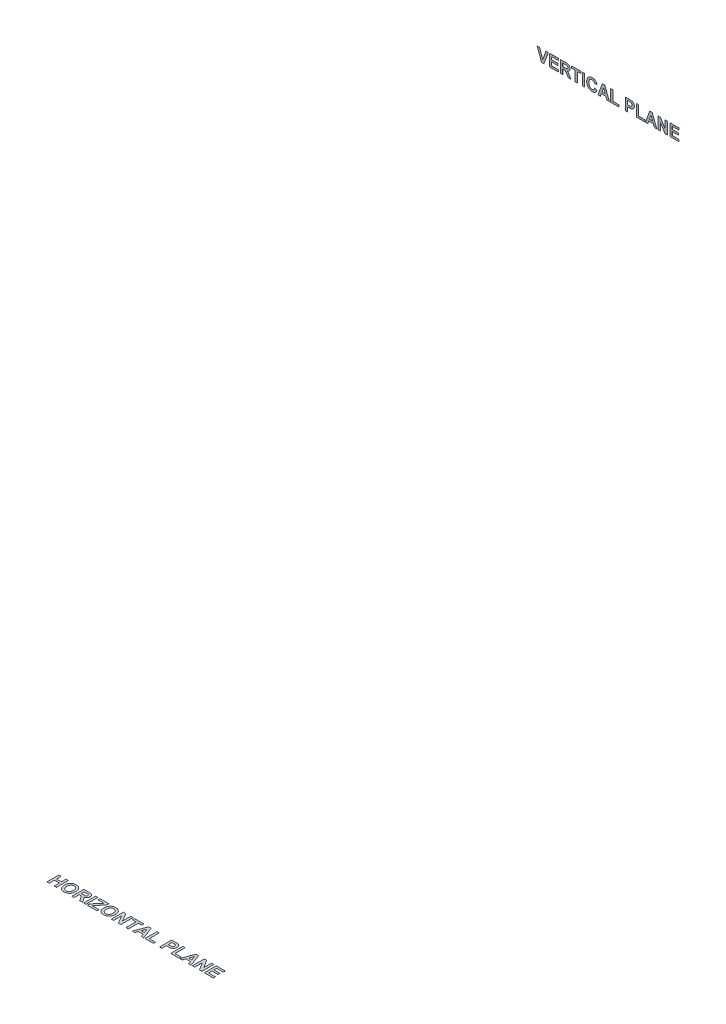
from build123d import *

# Parameters (mm, degrees)
VERTICAL_PLANE_TEXT_DEPTH      = 0.01
VERTICAL_PLANE_TEXT_2_DEPTH    = 0.01
VERTICAL_PLANE_TEXT_3_DEPTH    = 0.01
VERTICAL_PLANE_TEXT_4_DEPTH    = 0.01
SKETCH6_W                      = 0.673076923
SKETCH6_H                      = 3.5
VERTICAL_PLANE_TEXT_5_DEPTH    = 0.01
VERTICAL_PLANE_TEXT_6_DEPTH    = 0.01
VERTICAL_PLANE_TEXT_7_DEPTH    = 0.01
VERTICAL_PLANE_TEXT_8_DEPTH    = 0.01
VERTICAL_PLANE_TEXT_9_DEPTH    = 0.01
VERTICAL_PLANE_TEXT_10_DEPTH   = 0.01
VERTICAL_PLANE_TEXT_11_DEPTH   = 0.01
VERTICAL_PLANE_TEXT_12_DEPTH   = 0.01
VERTICAL_PLANE_TEXT_13_DEPTH   = 0.01
HORIZONTAL_PLANE_TEXT_DEPTH    = 0.01
HORIZONTAL_PLANE_TEXT_2_DEPTH  = 0.01
HORIZONTAL_PLANE_TEXT_3_DEPTH  = 0.01
SKETCH7_W                      = 0.673076923
SKETCH7_H                      = 3.5
HORIZONTAL_PLANE_TEXT_4_DEPTH  = 0.01
HORIZONTAL_PLANE_TEXT_5_DEPTH  = 0.01
HORIZONTAL_PLANE_TEXT_6_DEPTH  = 0.01
HORIZONTAL_PLANE_TEXT_7_DEPTH  = 0.01
HORIZONTAL_PLANE_TEXT_8_DEPTH  = 0.01
HORIZONTAL_PLANE_TEXT_9_DEPTH  = 0.01
HORIZONTAL_PLANE_TEXT_10_DEPTH = 0.01
HORIZONTAL_PLANE_TEXT_11_DEPTH = 0.01
HORIZONTAL_PLANE_TEXT_12_DEPTH = 0.01
HORIZONTAL_PLANE_TEXT_13_DEPTH = 0.01
HORIZONTAL_PLANE_TEXT_14_DEPTH = 0.01
HORIZONTAL_PLANE_TEXT_15_DEPTH = 0.01


with BuildPart() as part:
    # Sketch6 → Vertical  Plane text (new body)
    with BuildSketch(Plane.XY):
        Polygon((162.928886218, 140), (161.634615385, 143.5), (162.345552885, 143.5), (163.272435897, 140.897435897), (164.195813301, 143.5), (164.91025641, 143.5), (163.620893429, 140), align=None)
    extrude(amount=VERTICAL_PLANE_TEXT_DEPTH)


with BuildPart() as body_2:
    # Sketch6 → Vertical Plane text 2 (new body)
    with BuildSketch(Plane.XY):
        Polygon((165.224358974, 140), (165.224358974, 143.5), (167.826923077, 143.5), (167.826923077, 142.916666667), (165.897435897, 142.916666667), (165.897435897, 142.153846154), (167.692307692, 142.153846154), (167.692307692, 141.570512821), (165.897435897, 141.570512821), (165.897435897, 140.583333333), (167.871794872, 140.583333333), (167.871794872, 140), align=None)
    extrude(amount=VERTICAL_PLANE_TEXT_2_DEPTH)


with BuildPart() as body_3:
    # Sketch6 → Vertical Plane text 3 (new body)
    with BuildSketch(Plane.XY):
        with BuildLine():
            Line((168.455128205, 140), (168.455128205, 143.5))
            Line((168.455128205, 143.5), (169.923978365, 143.5))
            add(Edge.make_bspline(
                [(169.923978365, 143.5), (169.968618174, 143.499724886), (170.054647254, 143.499194691), (170.179062088, 143.495328401), (170.293800492, 143.487228299), (170.399371448, 143.478054866), (170.49526789, 143.464708113), (170.581868975, 143.448718835), (170.659028904, 143.430189465), (170.727873486, 143.40799754), (170.79064576, 143.382598111), (170.849121213, 143.352365645), (170.9039428, 143.316944595), (170.955952526, 143.277555827), (171.005370633, 143.234138819), (171.050842337, 143.185544544), (171.093159877, 143.132496584), (171.132289108, 143.075436302), (171.166759511, 143.014615654), (171.198256409, 142.951987908), (171.223896072, 142.886886612), (171.245074201, 142.819618441), (171.261991617, 142.750329442), (171.273733733, 142.678843459), (171.281064209, 142.605289882), (171.281718602, 142.555606574), (171.282051282, 142.530348558)],
                knots=[0, 0, 0, 0, 1.675828044, 3.229627355, 4.67171229, 5.993455049, 7.206927059, 8.304770529, 9.29850117, 10.183580433, 11.017754134, 11.837875825, 12.650738409, 13.464925643, 14.285328857, 15.117007378, 15.959673368, 16.830859064, 17.711229498, 18.58228265, 19.460420693, 20.334473227, 21.228207035, 22.135446768, 23.052097822, 24, 24, 24, 24], degree=3))
            add(Edge.make_bspline(
                [(171.282051282, 142.530348558), (171.28143421, 142.498530526), (171.280228281, 142.436349323), (171.269130685, 142.345211031), (171.252647921, 142.258134898), (171.229151868, 142.175000289), (171.196845273, 142.096784985), (171.159341265, 142.022393301), (171.114611436, 141.952077575), (171.062959675, 141.88653488), (171.004432224, 141.825707197), (170.938772594, 141.770846314), (170.866449573, 141.721737821), (170.787025652, 141.678664908), (170.701053862, 141.641842234), (170.608161404, 141.610860758), (170.5087688, 141.585645288), (170.43963136, 141.573780656), (170.404246795, 141.567708333)],
                knots=[0, 0, 0, 0, 1.05911256, 2.069797862, 3.05271628, 4.008392045, 4.940519534, 5.866323021, 6.779546087, 7.71056835, 8.640711998, 9.585328432, 10.554502533, 11.547017206, 12.589327225, 13.664782803, 14.804835066, 16, 16, 16, 16], degree=3))
            add(Edge.make_bspline(
                [(170.404246795, 141.567708333), (170.438467643, 141.545043544), (170.505442505, 141.500685463), (170.598107047, 141.427627148), (170.68129782, 141.350946796), (170.744285676, 141.282757856), (170.792685353, 141.222793009), (170.831655362, 141.170347176), (170.873690764, 141.109989629), (170.918379283, 141.041687666), (170.967042025, 140.966045596), (171.017869136, 140.881905603), (171.071924245, 140.790088399), (171.108267738, 140.725949433), (171.127103365, 140.692708333)],
                knots=[0, 0, 0, 0, 1.285445069, 2.515791127, 3.691898215, 4.826622834, 5.420063933, 6.105349801, 6.873086501, 7.723915395, 8.66222816, 9.690593598, 10.803111229, 12, 12, 12, 12], degree=3))
            Line((171.127103365, 140.692708333), (171.551282051, 140))
            Line((171.551282051, 140), (170.764623397, 140))
            Line((170.764623397, 140), (170.266826923, 140.794370994))
            add(Edge.make_bspline(
                [(170.266826923, 140.794370994), (170.243965141, 140.826184979), (170.2003173, 140.886924416), (170.137308944, 140.973237129), (170.079661891, 141.050070946), (170.02891032, 141.11853876), (169.982486224, 141.176699348), (169.941799223, 141.225566247), (169.907678058, 141.266188071), (169.869069876, 141.306466362), (169.824153355, 141.347861226), (169.768550289, 141.387995903), (169.7114511, 141.419990844), (169.650273879, 141.444403736), (169.579524272, 141.461426026), (169.49447204, 141.472271389), (169.392442942, 141.480272976), (169.318696345, 141.480595427), (169.278946314, 141.480769231)],
                knots=[0, 0, 0, 0, 1.465447777, 2.797841088, 3.997266218, 5.05856206, 5.985598736, 6.780315439, 7.437430484, 7.969193402, 8.866571936, 9.718200644, 10.52825214, 11.309096006, 12.174169268, 13.242355782, 14.513606761, 16, 16, 16, 16], degree=3))
            Line((169.278946314, 141.480769231), (169.128205128, 141.480769231))
            Line((169.128205128, 141.480769231), (169.128205128, 140))
            Line((169.128205128, 140), (168.455128205, 140))
        make_face()
        with BuildLine():
            Line((169.128205128, 142.064102564), (169.670172276, 142.064102564))
            add(Edge.make_bspline(
                [(169.670172276, 142.064102564), (169.712007896, 142.06419222), (169.791711822, 142.064363031), (169.90505239, 142.06683715), (170.006303682, 142.068937078), (170.094859785, 142.074213237), (170.171116906, 142.079442407), (170.234769139, 142.086238432), (170.286352772, 142.094271114), (170.337876151, 142.106759825), (170.390653597, 142.128518938), (170.44690437, 142.159510321), (170.494980513, 142.199714548), (170.536625557, 142.246194701), (170.568394891, 142.300836348), (170.593277794, 142.361205142), (170.605893953, 142.428642531), (170.607926042, 142.475385424), (170.608974359, 142.499499199)],
                knots=[0, 0, 0, 0, 1.697953026, 3.23488743, 4.60134403, 5.807846676, 6.835100678, 7.703488618, 8.405232423, 8.952775585, 9.851109663, 10.713519226, 11.549115941, 12.382556273, 13.233359028, 14.101746968, 15.020727134, 16, 16, 16, 16], degree=3))
            add(Edge.make_bspline(
                [(170.608974359, 142.499499199), (170.607782096, 142.526475442), (170.605481816, 142.578521752), (170.587341486, 142.652584149), (170.555678277, 142.718008079), (170.512192674, 142.774901559), (170.457603349, 142.822943235), (170.392581428, 142.861077869), (170.317609975, 142.889478961), (170.263535722, 142.89996743), (170.235276442, 142.905448718)],
                knots=[0, 0, 0, 0, 1.062977961, 2.050844577, 2.982300261, 3.90936959, 4.856017476, 5.831122378, 6.86654153, 8, 8, 8, 8], degree=3))
            add(Edge.make_bspline(
                [(170.235276442, 142.905448718), (170.225935309, 142.906475108), (170.203794861, 142.908907867), (170.164697454, 142.910470322), (170.114706404, 142.912871985), (170.053216619, 142.913853491), (169.980777445, 142.915573984), (169.897100831, 142.91588991), (169.802452625, 142.916899272), (169.735610715, 142.91674704), (169.700320513, 142.916666667)],
                knots=[0, 0, 0, 0, 0.42127143, 0.998501726, 1.753681744, 2.66564073, 3.755712164, 5.002818897, 6.417592707, 8, 8, 8, 8], degree=3))
            Line((169.700320513, 142.916666667), (169.128205128, 142.916666667))
            Line((169.128205128, 142.916666667), (169.128205128, 142.064102564))
        make_face(mode=Mode.SUBTRACT)
    extrude(amount=VERTICAL_PLANE_TEXT_3_DEPTH)


with BuildPart() as body_4:
    # Sketch6 → Vertical Plane text 4 (new body)
    with BuildSketch(Plane.XY):
        Polygon((172.762820513, 140), (172.762820513, 142.916666667), (171.730769231, 142.916666667), (171.730769231, 143.5), (174.467948718, 143.5), (174.467948718, 142.916666667), (173.435897436, 142.916666667), (173.435897436, 140), align=None)
    extrude(amount=VERTICAL_PLANE_TEXT_4_DEPTH)


with BuildPart() as body_5:
    # Sketch6 → Vertical Plane text 5 (new body)
    with BuildSketch(Plane.XY):
        with Locations((175.208333334, 141.75)):
            Rectangle(SKETCH6_W, SKETCH6_H)
    extrude(amount=VERTICAL_PLANE_TEXT_5_DEPTH)


with BuildPart() as body_6:
    # Sketch6 → Vertical Plane text 6 (new body)
    with BuildSketch(Plane.XY):
        with BuildLine():
            Line((178.506410256, 141.301282051), (179.179487179, 141.076923077))
            add(Edge.make_bspline(
                [(179.179487179, 141.076923077), (179.165808185, 141.032791119), (179.13902041, 140.946366861), (179.089833565, 140.82250038), (179.03358917, 140.707707664), (178.972309898, 140.600645141), (178.902184914, 140.504078584), (178.827140184, 140.414810732), (178.744944331, 140.334721735), (178.656002931, 140.263640574), (178.561172095, 140.200781957), (178.459350261, 140.147641881), (178.352056977, 140.10187371), (178.238204228, 140.064791842), (178.118547618, 140.035094895), (177.992525709, 140.015479899), (177.860728019, 140.002180285), (177.770734663, 140.000738283), (177.724659455, 140)],
                knots=[0, 0, 0, 0, 1.126640671, 2.206316847, 3.246446654, 4.24268115, 5.210795778, 6.153057602, 7.084219323, 8.004711971, 8.926421631, 9.854560063, 10.802134612, 11.768317461, 12.772025444, 13.805668576, 14.876536225, 16, 16, 16, 16], degree=3))
            add(Edge.make_bspline(
                [(177.724659455, 140), (177.667789026, 140.001175957), (177.555923193, 140.0034891), (177.392330006, 140.026774076), (177.236433097, 140.063104192), (177.088009443, 140.113402605), (176.948049754, 140.180022725), (176.815277119, 140.260224713), (176.690657809, 140.3556368), (176.574629011, 140.464650924), (176.469214042, 140.58643488), (176.378057365, 140.720330582), (176.300167136, 140.864451767), (176.237212237, 141.019485619), (176.187985755, 141.185272947), (176.153502502, 141.361584522), (176.131925075, 141.548475884), (176.129466775, 141.676554972), (176.128205128, 141.74228766)],
                knots=[0, 0, 0, 0, 1.025049111, 2.016302254, 2.973197159, 3.90886983, 4.83646737, 5.763135642, 6.70136783, 7.661478232, 8.629732022, 9.600038443, 10.576877021, 11.5787097, 12.612181225, 13.690866959, 14.814907849, 16, 16, 16, 16], degree=3))
            add(Edge.make_bspline(
                [(176.128205128, 141.74228766), (176.129461089, 141.811525037), (176.131911238, 141.946594525), (176.153529088, 142.142973997), (176.187089512, 142.328050202), (176.236399194, 142.500675592), (176.298428961, 142.662065046), (176.376413756, 142.810616464), (176.466661149, 142.948310441), (176.571597693, 143.072623216), (176.688155279, 143.18299615), (176.813061148, 143.280595663), (176.947480561, 143.362474657), (177.090677943, 143.429431013), (177.242845349, 143.481245137), (177.403683353, 143.518555374), (177.57332355, 143.54027233), (177.689307395, 143.543317665), (177.748497596, 143.544871795)],
                knots=[0, 0, 0, 0, 1.212648312, 2.365655595, 3.457000981, 4.504219827, 5.506356588, 6.480637568, 7.437950897, 8.385265166, 9.323599949, 10.245787653, 11.157260172, 12.074946661, 13.00980897, 13.968233668, 14.963125779, 16, 16, 16, 16], degree=3))
            add(Edge.make_bspline(
                [(177.748497596, 143.544871795), (177.800190686, 143.543569263), (177.901541869, 143.541015476), (178.049960384, 143.523664953), (178.190619601, 143.493215945), (178.324279829, 143.452116554), (178.4501802, 143.397876291), (178.568546265, 143.331595248), (178.679784875, 143.25362412), (178.746808428, 143.192719435), (178.780548878, 143.162059295)],
                knots=[0, 0, 0, 0, 1.098510076, 2.153775193, 3.169777012, 4.153122333, 5.120892526, 6.076995459, 7.031936742, 8, 8, 8, 8], degree=3))
            add(Edge.make_bspline(
                [(178.780548878, 143.162059295), (178.8001044, 143.142549936), (178.839674789, 143.103072959), (178.892512365, 143.036424635), (178.942608951, 142.964677704), (178.989169415, 142.886608253), (179.030722183, 142.801626311), (179.069266815, 142.711036932), (179.104753411, 142.614490923), (179.124488039, 142.547300866), (179.134615385, 142.512820513)],
                knots=[0, 0, 0, 0, 0.885292881, 1.791380647, 2.722937556, 3.69093542, 4.703306561, 5.754477758, 6.847650944, 8, 8, 8, 8], degree=3))
            Line((179.134615385, 142.512820513), (178.461538462, 142.378205128))
            add(Edge.make_bspline(
                [(178.461538462, 142.378205128), (178.455817584, 142.40028209), (178.444548957, 142.443767913), (178.421748424, 142.506254653), (178.395594414, 142.565548989), (178.363178915, 142.620198594), (178.328745272, 142.672634677), (178.287977782, 142.720528912), (178.24348, 142.765136503), (178.194931371, 142.805994531), (178.142910664, 142.842277396), (178.088419462, 142.874893432), (178.030467366, 142.901518308), (177.969825281, 142.923057771), (177.906734739, 142.941116988), (177.840634041, 142.952273008), (177.772090914, 142.960837226), (177.725390054, 142.96130129), (177.701522436, 142.961538462)],
                knots=[0, 0, 0, 0, 1.051226935, 2.070641259, 3.064374968, 4.034983734, 4.997599858, 5.953980297, 6.92954377, 7.901109626, 8.875958313, 9.851998019, 10.826131395, 11.811470594, 12.818270757, 13.847890818, 14.900111925, 16, 16, 16, 16], degree=3))
            add(Edge.make_bspline(
                [(177.701522436, 142.961538462), (177.668744689, 142.9608765), (177.604772335, 142.95958455), (177.511266938, 142.945180183), (177.422145667, 142.925077397), (177.337767944, 142.894380547), (177.258656297, 142.85511953), (177.183911618, 142.807393373), (177.113944146, 142.7514065), (177.048730232, 142.68649565), (176.990209609, 142.611487203), (176.938761628, 142.526226294), (176.896080915, 142.429744935), (176.861430965, 142.322989913), (176.834157506, 142.205707362), (176.814682109, 142.077746862), (176.803911629, 141.939020874), (176.802177491, 141.84303359), (176.801282051, 141.793469551)],
                knots=[0, 0, 0, 0, 0.938194206, 1.831074359, 2.704771284, 3.551924377, 4.396294915, 5.230222094, 6.087631332, 6.958733431, 7.860107878, 8.806247581, 9.804197948, 10.875520245, 12.017191412, 13.250061517, 14.580040491, 16, 16, 16, 16], degree=3))
            add(Edge.make_bspline(
                [(176.801282051, 141.793469551), (176.802168674, 141.740868404), (176.80387706, 141.639514095), (176.814645255, 141.493319878), (176.834245188, 141.358859874), (176.861156183, 141.235895464), (176.895980748, 141.124501963), (176.938589282, 141.024872138), (176.989242699, 140.93688931), (177.047862191, 140.860612065), (177.112965757, 140.795090147), (177.182790117, 140.738756215), (177.256923321, 140.690590926), (177.33581147, 140.650963631), (177.419754611, 140.620986023), (177.508062856, 140.599245737), (177.601060223, 140.585425091), (177.664780857, 140.584040358), (177.697315705, 140.583333333)],
                knots=[0, 0, 0, 0, 1.475208372, 2.842499301, 4.107722225, 5.282836115, 6.369007568, 7.375918121, 8.315702116, 9.208439171, 10.065831443, 10.90006451, 11.71996243, 12.54067204, 13.369972975, 14.214060185, 15.088124569, 16, 16, 16, 16], degree=3))
            add(Edge.make_bspline(
                [(177.697315705, 140.583333333), (177.72140332, 140.583934281), (177.768768038, 140.585115956), (177.838776744, 140.592615956), (177.905970823, 140.606928625), (177.97067917, 140.625854538), (178.033153198, 140.649600977), (178.092439972, 140.680062882), (178.149705935, 140.715074319), (178.203762864, 140.75610504), (178.255334607, 140.802169858), (178.302371097, 140.855409307), (178.346001347, 140.914544164), (178.38567184, 140.979969628), (178.422708095, 141.05112568), (178.454218729, 141.129120971), (178.483573709, 141.212695059), (178.498665118, 141.271237293), (178.506410256, 141.301282051)],
                knots=[0, 0, 0, 0, 0.980177776, 1.927374078, 2.859849964, 3.771585772, 4.668674471, 5.574490016, 6.479656464, 7.396337719, 8.332153134, 9.288470092, 10.28125149, 11.318486971, 12.398724812, 13.541284404, 14.738150009, 16, 16, 16, 16], degree=3))
        make_face()
    extrude(amount=VERTICAL_PLANE_TEXT_6_DEPTH)


with BuildPart() as body_7:
    # Sketch6 → Vertical Plane text 7 (new body)
    with BuildSketch(Plane.XY):
        Polygon((182.769230769, 140), (182.055488782, 140), (181.760316506, 140.807692308), (180.416967147, 140.807692308), (180.121794872, 140), (179.403846154, 140), (180.726862981, 143.5), (181.439903846, 143.5), align=None)
        Polygon((181.546474359, 141.391025641), (181.086538462, 142.647435897), (180.628004808, 141.391025641), align=None, mode=Mode.SUBTRACT)
    extrude(amount=VERTICAL_PLANE_TEXT_7_DEPTH)


with BuildPart() as body_8:
    # Sketch6 → Vertical Plane text 8 (new body)
    with BuildSketch(Plane.XY):
        Polygon((183.128205128, 140), (183.128205128, 143.5), (183.801282051, 143.5), (183.801282051, 140.583333333), (185.596153846, 140.583333333), (185.596153846, 140), align=None)
    extrude(amount=VERTICAL_PLANE_TEXT_8_DEPTH)


with BuildPart() as body_9:
    # Sketch6 → Vertical Plane text 9 (new body)
    with BuildSketch(Plane.XY):
        with BuildLine():
            Line((187.435897436, 140), (187.435897436, 143.5))
            Line((187.435897436, 143.5), (188.555588942, 143.5))
            add(Edge.make_bspline(
                [(188.555588942, 143.5), (188.606305077, 143.499944616), (188.703305712, 143.499838686), (188.841671252, 143.496895527), (188.966248691, 143.492729161), (189.076853137, 143.487540128), (189.173873777, 143.479797095), (189.256875388, 143.470830779), (189.326380625, 143.461185402), (189.3673102, 143.451203727), (189.385717147, 143.446714744)],
                knots=[0, 0, 0, 0, 1.460485487, 2.793352117, 3.985295279, 5.050041172, 5.981765236, 6.787433016, 7.454681457, 8, 8, 8, 8], degree=3))
            add(Edge.make_bspline(
                [(189.385717147, 143.446714744), (189.410193911, 143.439735475), (189.458774552, 143.425883262), (189.528375461, 143.396352545), (189.595459717, 143.362128019), (189.659184476, 143.32133857), (189.71976636, 143.274708355), (189.777385446, 143.22261765), (189.832349008, 143.164831306), (189.883896695, 143.101463476), (189.931108313, 143.032833695), (189.971911013, 142.958840494), (190.006095144, 142.879805486), (190.035219456, 142.796322609), (190.056707512, 142.707496792), (190.071745244, 142.613945206), (190.082213383, 142.515626933), (190.082954559, 142.448345926), (190.083333333, 142.41396234)],
                knots=[0, 0, 0, 0, 0.907145743, 1.80047177, 2.69161667, 3.591261238, 4.495029544, 5.415863088, 6.359363025, 7.337192411, 8.326890979, 9.326929023, 10.346104993, 11.395420813, 12.477187422, 13.601053412, 14.774031606, 16, 16, 16, 16], degree=3))
            add(Edge.make_bspline(
                [(190.083333333, 142.41396234), (190.082253071, 142.361746954), (190.080173508, 142.26122947), (190.056906879, 142.117125474), (190.021419548, 141.985495762), (189.969552248, 141.867608204), (189.906315235, 141.763000188), (189.836658364, 141.668696555), (189.757120453, 141.587539713), (189.671186757, 141.51821994), (189.580370545, 141.461491513), (189.489389938, 141.413131335), (189.397017285, 141.375950484), (189.334037816, 141.359750489), (189.302984776, 141.351762821)],
                knots=[0, 0, 0, 0, 1.312386234, 2.526415563, 3.661883817, 4.733421185, 5.753802465, 6.732107337, 7.675884281, 8.604170108, 9.50284679, 10.365392406, 11.194030444, 12, 12, 12, 12], degree=3))
            add(Edge.make_bspline(
                [(189.302984776, 141.351762821), (189.280820639, 141.347546681), (189.234101282, 141.338659561), (189.160007178, 141.329800721), (189.079018307, 141.31999495), (188.990801555, 141.313599075), (188.895463643, 141.307609607), (188.79304159, 141.304781781), (188.683681769, 141.301374825), (188.60841016, 141.301313606), (188.569611378, 141.301282051)],
                knots=[0, 0, 0, 0, 0.735353946, 1.55003838, 2.431865514, 3.394945452, 4.432993119, 5.54609699, 6.735134699, 8, 8, 8, 8], degree=3))
            Line((188.569611378, 141.301282051), (188.108974359, 141.301282051))
            Line((188.108974359, 141.301282051), (188.108974359, 140))
            Line((188.108974359, 140), (187.435897436, 140))
        make_face()
        with BuildLine():
            Line((188.108974359, 142.916666667), (188.108974359, 141.884615385))
            Line((188.108974359, 141.884615385), (188.512820513, 141.884615385))
            add(Edge.make_bspline(
                [(188.512820513, 141.884615385), (188.547645954, 141.884660481), (188.614271404, 141.884746755), (188.709864146, 141.887843498), (188.796394787, 141.891623646), (188.874044129, 141.897880566), (188.942343461, 141.906127036), (189.001750165, 141.915990853), (189.052333481, 141.926575759), (189.10703245, 141.944116645), (189.165516584, 141.972496198), (189.227970766, 142.013284745), (189.282836691, 142.062052263), (189.328492413, 142.119328024), (189.364961227, 142.182964713), (189.391072924, 142.252310161), (189.407933223, 142.32621507), (189.409473257, 142.377410916), (189.41025641, 142.403445513)],
                knots=[0, 0, 0, 0, 1.411705958, 2.700771114, 3.876961699, 4.922619712, 5.858038221, 6.66485904, 7.363650596, 7.950905807, 8.989198271, 9.987739806, 10.967313358, 11.951275539, 12.944273208, 13.927870418, 14.946261014, 16, 16, 16, 16], degree=3))
            add(Edge.make_bspline(
                [(189.41025641, 142.403445513), (189.409154208, 142.435155246), (189.407017184, 142.496636237), (189.383451773, 142.584195429), (189.347093036, 142.663656457), (189.295110366, 142.73254693), (189.232316523, 142.790478152), (189.161738864, 142.838678989), (189.081870172, 142.872410302), (189.025344546, 142.88547994), (188.996594551, 142.892127404)],
                knots=[0, 0, 0, 0, 1.085904563, 2.105425768, 3.088705091, 4.068969419, 5.045188284, 6.010769642, 6.988240112, 8, 8, 8, 8], degree=3))
            add(Edge.make_bspline(
                [(188.996594551, 142.892127404), (188.984222772, 142.894106169), (188.956761257, 142.898498414), (188.911114632, 142.903082269), (188.857114666, 142.907251279), (188.79469627, 142.910674162), (188.724106852, 142.913350063), (188.645113579, 142.915694813), (188.557924493, 142.915883183), (188.496927848, 142.91639827), (188.465144231, 142.916666667)],
                knots=[0, 0, 0, 0, 0.564603001, 1.253243608, 2.066786758, 3.005752288, 4.070476343, 5.250658742, 6.567396469, 8, 8, 8, 8], degree=3))
            Line((188.465144231, 142.916666667), (188.108974359, 142.916666667))
        make_face(mode=Mode.SUBTRACT)
    extrude(amount=VERTICAL_PLANE_TEXT_9_DEPTH)


with BuildPart() as body_10:
    # Sketch6 → Vertical Plane text 10 (new body)
    with BuildSketch(Plane.XY):
        Polygon((190.666666667, 140), (190.666666667, 143.5), (191.33974359, 143.5), (191.33974359, 140.583333333), (193.134615385, 140.583333333), (193.134615385, 140), align=None)
    extrude(amount=VERTICAL_PLANE_TEXT_10_DEPTH)


with BuildPart() as body_11:
    # Sketch6 → Vertical Plane text 11 (new body)
    with BuildSketch(Plane.XY):
        Polygon((196.634615385, 140), (195.920873397, 140), (195.625701122, 140.807692308), (194.282351763, 140.807692308), (193.987179487, 140), (193.269230769, 140), (194.592247596, 143.5), (195.305288462, 143.5), align=None)
        Polygon((195.411858974, 141.391025641), (194.951923077, 142.647435897), (194.493389423, 141.391025641), align=None, mode=Mode.SUBTRACT)
    extrude(amount=VERTICAL_PLANE_TEXT_11_DEPTH)


with BuildPart() as body_12:
    # Sketch6 → Vertical Plane text 12 (new body)
    with BuildSketch(Plane.XY):
        Polygon((196.993589744, 140), (196.993589744, 143.5), (197.696814904, 143.5), (199.102564103, 141.200320513), (199.102564103, 143.5), (199.775641026, 143.5), (199.775641026, 140), (199.051382212, 140), (197.666666667, 142.264623397), (197.666666667, 140), align=None)
    extrude(amount=VERTICAL_PLANE_TEXT_12_DEPTH)


with BuildPart() as body_13:
    # Sketch6 → Vertical Plane text 13 (new body)
    with BuildSketch(Plane.XY):
        Polygon((200.493589744, 140), (200.493589744, 143.5), (203.096153846, 143.5), (203.096153846, 142.916666667), (201.166666667, 142.916666667), (201.166666667, 142.153846154), (202.961538462, 142.153846154), (202.961538462, 141.570512821), (201.166666667, 141.570512821), (201.166666667, 140.583333333), (203.141025641, 140.583333333), (203.141025641, 140), align=None)
    extrude(amount=VERTICAL_PLANE_TEXT_13_DEPTH)


with BuildPart() as body_14:
    # Sketch7 → Horizontal Plane text (new body)
    with BuildSketch(Plane(origin=(0, 0, 0), x_dir=(1, 0, 0), z_dir=(0, 1, 0))):
        Polygon((158.224358974, -140), (158.224358974, -136.5), (158.897435897, -136.5), (158.897435897, -137.891025641), (160.333333333, -137.891025641), (160.333333333, -136.5), (161.006410256, -136.5), (161.006410256, -140), (160.333333333, -140), (160.333333333, -138.474358974), (158.897435897, -138.474358974), (158.897435897, -140), align=None)
    extrude(amount=HORIZONTAL_PLANE_TEXT_DEPTH)


with BuildPart() as body_15:
    # Sketch7 → Horizontal Plane text 2 (new body)
    with BuildSketch(Plane(origin=(0, 0, 0), x_dir=(1, 0, 0), z_dir=(0, 1, 0))):
        with BuildLine():
            add(Edge.make_bspline(
                [(161.58974359, -138.271033654), (161.58999127, -138.227782098), (161.590477683, -138.142841626), (161.598906091, -138.018230765), (161.610015388, -137.898786602), (161.628106861, -137.784978954), (161.649389038, -137.676275164), (161.676007393, -137.572707498), (161.708073085, -137.474639165), (161.733581596, -137.412023595), (161.74609375, -137.381310096)],
                knots=[0, 0, 0, 0, 1.141009212, 2.240794809, 3.294380675, 4.305229195, 5.280013876, 6.216333343, 7.125095522, 8, 8, 8, 8], degree=3))
            add(Edge.make_bspline(
                [(161.74609375, -137.381310096), (161.766546373, -137.3376473), (161.807211062, -137.250835255), (161.88273178, -137.128162856), (161.968330062, -137.012472844), (162.0633012, -136.904371714), (162.165220551, -136.805486868), (162.274568922, -136.720855678), (162.387461495, -136.647619968), (162.467753744, -136.61078676), (162.507512019, -136.592548077)],
                knots=[0, 0, 0, 0, 1.031372299, 2.050613973, 3.077158538, 4.108712802, 5.127684358, 6.111366908, 7.06480644, 8, 8, 8, 8], degree=3))
            add(Edge.make_bspline(
                [(162.507512019, -136.592548077), (162.534499787, -136.581478297), (162.589048948, -136.559103448), (162.673824765, -136.531178464), (162.761817216, -136.508490678), (162.852389858, -136.48821044), (162.946422075, -136.474226548), (163.043154047, -136.462501536), (163.143115156, -136.456356253), (163.210730118, -136.455542006), (163.245092147, -136.455128205)],
                knots=[0, 0, 0, 0, 0.92659354, 1.872881803, 2.832850937, 3.813025581, 4.820167273, 5.851730198, 6.908245912, 8, 8, 8, 8], degree=3))
            add(Edge.make_bspline(
                [(163.245092147, -136.455128205), (163.306620023, -136.456670507), (163.42703092, -136.459688813), (163.602917428, -136.481489677), (163.769359468, -136.518302443), (163.925793631, -136.571510534), (164.073568643, -136.638021804), (164.211536382, -136.720521459), (164.339901041, -136.818116603), (164.458414692, -136.929468891), (164.565144723, -137.054384265), (164.658097713, -137.191695829), (164.736072705, -137.340760129), (164.800289613, -137.501165889), (164.849635468, -137.673437045), (164.885287802, -137.857087516), (164.906468175, -138.052252577), (164.908971016, -138.186144453), (164.91025641, -138.254907853)],
                knots=[0, 0, 0, 0, 1.064641025, 2.083517118, 3.061799897, 4.009540929, 4.938075217, 5.861300345, 6.78508344, 7.723570974, 8.670267188, 9.622657076, 10.586935816, 11.576069104, 12.607749008, 13.683335114, 14.81022093, 16, 16, 16, 16], degree=3))
            add(Edge.make_bspline(
                [(164.91025641, -138.254907853), (164.909000705, -138.323210802), (164.90655608, -138.456183885), (164.884980363, -138.649817477), (164.850806122, -138.832129131), (164.800266294, -139.002702382), (164.737965991, -139.162838816), (164.659188617, -139.310631081), (164.568182343, -139.448039544), (164.461603902, -139.571608857), (164.345084904, -139.683600197), (164.216883068, -139.780054698), (164.079919667, -139.862666137), (163.932950352, -139.929369613), (163.776933041, -139.981481903), (163.611358582, -140.018577548), (163.436142058, -140.040294519), (163.316200319, -140.043323784), (163.254907853, -140.044871795)],
                knots=[0, 0, 0, 0, 1.18845052, 2.313691126, 3.386664782, 4.412527756, 5.405809582, 6.372003093, 7.321919452, 8.268293321, 9.206237639, 10.129603466, 11.054616372, 11.9847576, 12.932764752, 13.912672021, 14.933336461, 16, 16, 16, 16], degree=3))
            add(Edge.make_bspline(
                [(163.254907853, -140.044871795), (163.192915266, -140.043320212), (163.071577963, -140.040283318), (162.894492591, -140.018632452), (162.727274524, -139.981524596), (162.570042838, -139.929229), (162.421725182, -139.86353883), (162.283690917, -139.781771562), (162.155863741, -139.684706196), (162.038371158, -139.574033093), (161.931858619, -139.450827075), (161.840981562, -139.31430211), (161.762200079, -139.167953406), (161.699572232, -139.009564131), (161.649310709, -138.840763908), (161.61505296, -138.660581445), (161.593435523, -138.469512654), (161.590996728, -138.338402589), (161.58974359, -138.271033654)],
                knots=[0, 0, 0, 0, 1.080878253, 2.11558926, 3.1052859, 4.062802436, 5.000434901, 5.928596448, 6.853693179, 7.793554778, 8.738606028, 9.68692032, 10.647726704, 11.63151566, 12.651483354, 13.714466703, 14.825613081, 16, 16, 16, 16], degree=3))
        make_face()
        with BuildLine():
            add(Edge.make_bspline(
                [(162.262820513, -138.247896635), (162.263492908, -138.296310881), (162.264794989, -138.390064149), (162.278663875, -138.526144748), (162.299711026, -138.653361023), (162.330663952, -138.771568587), (162.369767083, -138.880852955), (162.417676525, -138.981305541), (162.474194287, -139.073075961), (162.540782203, -139.154226809), (162.612825108, -139.226678875), (162.690588997, -139.289368184), (162.772624623, -139.343325255), (162.860351454, -139.38592418), (162.951943736, -139.419731087), (163.048113078, -139.444797671), (163.149337656, -139.458561687), (163.218410498, -139.46053556), (163.253505609, -139.461538462)],
                knots=[0, 0, 0, 0, 1.313550922, 2.543666373, 3.708465049, 4.810029406, 5.85539231, 6.85404609, 7.825601258, 8.772642133, 9.696587791, 10.59409323, 11.479048685, 12.35559886, 13.234601248, 14.125357077, 15.047515647, 16, 16, 16, 16], degree=3))
            add(Edge.make_bspline(
                [(163.253505609, -139.461538462), (163.288605448, -139.46055588), (163.357687596, -139.458622001), (163.458787799, -139.444576561), (163.555147723, -139.420584384), (163.646376136, -139.386950718), (163.732888845, -139.343675374), (163.814610496, -139.290927907), (163.891070026, -139.227953389), (163.963034513, -139.156553871), (164.027825062, -139.074864027), (164.083861621, -138.983109444), (164.131747458, -138.88204761), (164.170854707, -138.771640716), (164.201045875, -138.651681034), (164.22123404, -138.522105092), (164.235215076, -138.383283388), (164.236511847, -138.287430607), (164.237179487, -138.238080929)],
                knots=[0, 0, 0, 0, 0.949153107, 1.868086493, 2.754172764, 3.630100905, 4.492260106, 5.365378617, 6.254840125, 7.166615376, 8.102436631, 9.067266169, 10.06813181, 11.121736829, 12.23011542, 13.408501285, 14.665770308, 16, 16, 16, 16], degree=3))
            add(Edge.make_bspline(
                [(164.237179487, -138.238080929), (164.236425379, -138.189207749), (164.234964976, -138.094560191), (164.222246376, -137.957490981), (164.201415661, -137.829969104), (164.172458664, -137.712027596), (164.134190173, -137.603647453), (164.08848294, -137.504532297), (164.033216403, -137.415199951), (163.969832457, -137.335696669), (163.899695202, -137.265718453), (163.823996246, -137.204455523), (163.742305495, -137.153481041), (163.655420237, -137.110592929), (163.562435906, -137.078774396), (163.464297441, -137.055566226), (163.360727116, -137.0412746), (163.289776267, -137.039413135), (163.253505609, -137.038461538)],
                knots=[0, 0, 0, 0, 1.332337092, 2.580197383, 3.749299508, 4.852775005, 5.886662144, 6.878700295, 7.822989687, 8.743523536, 9.644687758, 10.519443927, 11.392806431, 12.264866173, 13.155606721, 14.065961015, 15.011303331, 16, 16, 16, 16], degree=3))
            add(Edge.make_bspline(
                [(163.253505609, -137.038461538), (163.217230366, -137.039398497), (163.14627055, -137.041231329), (163.042538782, -137.055759574), (162.944091149, -137.0782762), (162.851119961, -137.111911575), (162.763477905, -137.154387824), (162.681489145, -137.207066839), (162.604507635, -137.268225801), (162.533741971, -137.339265048), (162.469331005, -137.419464529), (162.414037853, -137.509888426), (162.366888293, -137.609549196), (162.328204813, -137.718741844), (162.299528392, -137.837766752), (162.277488175, -137.965824001), (162.265111207, -138.103688669), (162.263600489, -138.198794174), (162.262820513, -138.247896635)],
                knots=[0, 0, 0, 0, 0.981996942, 1.920933313, 2.83127778, 3.712125466, 4.592427284, 5.463259035, 6.34592384, 7.249932058, 8.173122297, 9.125107726, 10.113123258, 11.154048744, 12.256187849, 13.424658091, 14.670364834, 16, 16, 16, 16], degree=3))
        make_face(mode=Mode.SUBTRACT)
    extrude(amount=HORIZONTAL_PLANE_TEXT_2_DEPTH)


with BuildPart() as body_16:
    # Sketch7 → Horizontal Plane text 3 (new body)
    with BuildSketch(Plane(origin=(0, 0, 0), x_dir=(1, 0, 0), z_dir=(0, 1, 0))):
        with BuildLine():
            Line((165.493589744, -140), (165.493589744, -136.5))
            Line((165.493589744, -136.5), (166.962439904, -136.5))
            add(Edge.make_bspline(
                [(166.962439904, -136.5), (167.007079712, -136.500275114), (167.093108793, -136.500805309), (167.217523627, -136.504671599), (167.332262031, -136.512771701), (167.437832987, -136.521945134), (167.533729428, -136.535291887), (167.620330513, -136.551281165), (167.697490442, -136.569810535), (167.766335025, -136.59200246), (167.829107299, -136.617401889), (167.887582752, -136.647634355), (167.942404338, -136.683055405), (167.994414065, -136.722444173), (168.043832171, -136.765861181), (168.089303876, -136.814455456), (168.131621415, -136.867503416), (168.170750646, -136.924563698), (168.205221049, -136.985384346), (168.236717947, -137.048012092), (168.26235761, -137.113113388), (168.283535739, -137.180381559), (168.300453155, -137.249670558), (168.312195271, -137.321156541), (168.319525748, -137.394710118), (168.32018014, -137.444393426), (168.320512821, -137.469651442)],
                knots=[0, 0, 0, 0, 1.675828044, 3.229627355, 4.67171229, 5.993455049, 7.206927059, 8.304770529, 9.29850117, 10.183580433, 11.017754134, 11.837875825, 12.650738409, 13.464925643, 14.285328857, 15.117007378, 15.959673368, 16.830859064, 17.711229498, 18.58228265, 19.460420693, 20.334473227, 21.228207035, 22.135446768, 23.052097822, 24, 24, 24, 24], degree=3))
            add(Edge.make_bspline(
                [(168.320512821, -137.469651442), (168.319895748, -137.501469474), (168.318689819, -137.563650677), (168.307592224, -137.654788969), (168.291109459, -137.741865102), (168.267613406, -137.824999711), (168.235306811, -137.903215015), (168.197802804, -137.977606699), (168.153072974, -138.047922425), (168.101421213, -138.11346512), (168.042893763, -138.174292803), (167.977234132, -138.229153686), (167.904911112, -138.278262179), (167.82548719, -138.321335092), (167.739515401, -138.358157766), (167.646622942, -138.389139242), (167.547230338, -138.414354712), (167.478092898, -138.426219344), (167.442708333, -138.432291667)],
                knots=[0, 0, 0, 0, 1.05911256, 2.069797862, 3.05271628, 4.008392045, 4.940519534, 5.866323021, 6.779546087, 7.71056835, 8.640711998, 9.585328432, 10.554502533, 11.547017206, 12.589327225, 13.664782803, 14.804835066, 16, 16, 16, 16], degree=3))
            add(Edge.make_bspline(
                [(167.442708333, -138.432291667), (167.476929181, -138.454956456), (167.543904043, -138.499314537), (167.636568586, -138.572372852), (167.719759358, -138.649053204), (167.782747215, -138.717242144), (167.831146891, -138.777206991), (167.8701169, -138.829652824), (167.912152302, -138.890010371), (167.956840821, -138.958312334), (168.005503564, -139.033954404), (168.056330675, -139.118094397), (168.110385784, -139.209911601), (168.146729277, -139.274050567), (168.165564904, -139.307291667)],
                knots=[0, 0, 0, 0, 1.285445069, 2.515791127, 3.691898215, 4.826622834, 5.420063933, 6.105349801, 6.873086501, 7.723915395, 8.66222816, 9.690593598, 10.803111229, 12, 12, 12, 12], degree=3))
            Line((168.165564904, -139.307291667), (168.58974359, -140))
            Line((168.58974359, -140), (167.803084936, -140))
            Line((167.803084936, -140), (167.305288462, -139.205629006))
            add(Edge.make_bspline(
                [(167.305288462, -139.205629006), (167.28242668, -139.173815021), (167.238778838, -139.113075584), (167.175770483, -139.026762871), (167.118123429, -138.949929054), (167.067371858, -138.88146124), (167.020947762, -138.823300652), (166.980260761, -138.774433753), (166.946139597, -138.733811929), (166.907531415, -138.693533638), (166.862614893, -138.652138774), (166.807011828, -138.612004097), (166.749912638, -138.580009156), (166.688735418, -138.555596264), (166.617985811, -138.538573974), (166.532933578, -138.527728611), (166.43090448, -138.519727024), (166.357157884, -138.519404573), (166.317407853, -138.519230769)],
                knots=[0, 0, 0, 0, 1.465447777, 2.797841088, 3.997266218, 5.05856206, 5.985598736, 6.780315439, 7.437430484, 7.969193402, 8.866571936, 9.718200644, 10.52825214, 11.309096006, 12.174169268, 13.242355782, 14.513606761, 16, 16, 16, 16], degree=3))
            Line((166.317407853, -138.519230769), (166.166666667, -138.519230769))
            Line((166.166666667, -138.519230769), (166.166666667, -140))
            Line((166.166666667, -140), (165.493589744, -140))
        make_face()
        with BuildLine():
            Line((166.166666667, -137.935897436), (166.708633814, -137.935897436))
            add(Edge.make_bspline(
                [(166.708633814, -137.935897436), (166.750469434, -137.93580778), (166.83017336, -137.935636969), (166.943513929, -137.93316285), (167.044765221, -137.931062922), (167.133321323, -137.925786763), (167.209578444, -137.920557593), (167.273230677, -137.913761568), (167.32481431, -137.905728886), (167.376337689, -137.893240175), (167.429115136, -137.871481062), (167.485365908, -137.840489679), (167.533442051, -137.800285452), (167.575087095, -137.753805299), (167.606856429, -137.699163652), (167.631739332, -137.638794858), (167.644355491, -137.571357469), (167.646387581, -137.524614576), (167.647435897, -137.500500801)],
                knots=[0, 0, 0, 0, 1.697953026, 3.23488743, 4.60134403, 5.807846676, 6.835100678, 7.703488618, 8.405232423, 8.952775585, 9.851109663, 10.713519226, 11.549115941, 12.382556273, 13.233359028, 14.101746968, 15.020727134, 16, 16, 16, 16], degree=3))
            add(Edge.make_bspline(
                [(167.647435897, -137.500500801), (167.646243634, -137.473524558), (167.643943355, -137.421478248), (167.625803024, -137.347415851), (167.594139815, -137.281991921), (167.550654212, -137.225098441), (167.496064888, -137.177056765), (167.431042966, -137.138922131), (167.356071514, -137.110521039), (167.301997261, -137.10003257), (167.273737981, -137.094551282)],
                knots=[0, 0, 0, 0, 1.062977961, 2.050844577, 2.982300261, 3.90936959, 4.856017476, 5.831122378, 6.86654153, 8, 8, 8, 8], degree=3))
            add(Edge.make_bspline(
                [(167.273737981, -137.094551282), (167.264396847, -137.093524892), (167.242256399, -137.091092133), (167.203158993, -137.089529678), (167.153167943, -137.087128015), (167.091678157, -137.086146509), (167.019238983, -137.084426016), (166.935562369, -137.08411009), (166.840914163, -137.083100728), (166.774072253, -137.08325296), (166.738782051, -137.083333333)],
                knots=[0, 0, 0, 0, 0.42127143, 0.998501726, 1.753681744, 2.66564073, 3.755712164, 5.002818897, 6.417592707, 8, 8, 8, 8], degree=3))
            Line((166.738782051, -137.083333333), (166.166666667, -137.083333333))
            Line((166.166666667, -137.083333333), (166.166666667, -137.935897436))
        make_face(mode=Mode.SUBTRACT)
    extrude(amount=HORIZONTAL_PLANE_TEXT_3_DEPTH)


with BuildPart() as body_17:
    # Sketch7 → Horizontal Plane text 4 (new body)
    with BuildSketch(Plane(origin=(0, 0, 0), x_dir=(1, 0, 0), z_dir=(0, 1, 0))):
        with Locations((169.285256411, -138.25)):
            Rectangle(SKETCH7_W, SKETCH7_H)
    extrude(amount=HORIZONTAL_PLANE_TEXT_4_DEPTH)


with BuildPart() as body_18:
    # Sketch7 → Horizontal Plane text 5 (new body)
    with BuildSketch(Plane(origin=(0, 0, 0), x_dir=(1, 0, 0), z_dir=(0, 1, 0))):
        Polygon((170.025641026, -140), (170.025641026, -139.371794872), (171.956530449, -137.083333333), (170.25, -137.083333333), (170.25, -136.5), (172.807692308, -136.5), (172.807692308, -137.083333333), (170.838241186, -139.416666667), (172.852564103, -139.416666667), (172.852564103, -140), align=None)
    extrude(amount=HORIZONTAL_PLANE_TEXT_5_DEPTH)


with BuildPart() as body_19:
    # Sketch7 → Horizontal Plane text 6 (new body)
    with BuildSketch(Plane(origin=(0, 0, 0), x_dir=(1, 0, 0), z_dir=(0, 1, 0))):
        with BuildLine():
            add(Edge.make_bspline(
                [(173.166666667, -138.271033654), (173.166914347, -138.227782098), (173.16740076, -138.142841626), (173.175829168, -138.018230765), (173.186938465, -137.898786602), (173.205029938, -137.784978954), (173.226312115, -137.676275164), (173.25293047, -137.572707498), (173.284996162, -137.474639165), (173.310504673, -137.412023595), (173.323016827, -137.381310096)],
                knots=[0, 0, 0, 0, 1.141009212, 2.240794809, 3.294380675, 4.305229195, 5.280013876, 6.216333343, 7.125095522, 8, 8, 8, 8], degree=3))
            add(Edge.make_bspline(
                [(173.323016827, -137.381310096), (173.34346945, -137.3376473), (173.384134139, -137.250835255), (173.459654857, -137.128162856), (173.545253139, -137.012472844), (173.640224277, -136.904371714), (173.742143627, -136.805486868), (173.851491999, -136.720855678), (173.964384572, -136.647619968), (174.044676821, -136.61078676), (174.084435096, -136.592548077)],
                knots=[0, 0, 0, 0, 1.031372299, 2.050613973, 3.077158538, 4.108712802, 5.127684358, 6.111366908, 7.06480644, 8, 8, 8, 8], degree=3))
            add(Edge.make_bspline(
                [(174.084435096, -136.592548077), (174.111422864, -136.581478297), (174.165972025, -136.559103448), (174.250747842, -136.531178464), (174.338740293, -136.508490678), (174.429312935, -136.48821044), (174.523345152, -136.474226548), (174.620077124, -136.462501536), (174.720038233, -136.456356253), (174.787653195, -136.455542006), (174.822015224, -136.455128205)],
                knots=[0, 0, 0, 0, 0.92659354, 1.872881803, 2.832850937, 3.813025581, 4.820167273, 5.851730198, 6.908245912, 8, 8, 8, 8], degree=3))
            add(Edge.make_bspline(
                [(174.822015224, -136.455128205), (174.8835431, -136.456670507), (175.003953997, -136.459688813), (175.179840505, -136.481489677), (175.346282545, -136.518302443), (175.502716708, -136.571510534), (175.65049172, -136.638021804), (175.788459459, -136.720521459), (175.916824118, -136.818116603), (176.035337769, -136.929468891), (176.1420678, -137.054384265), (176.23502079, -137.191695829), (176.312995782, -137.340760129), (176.37721269, -137.501165889), (176.426558545, -137.673437045), (176.462210879, -137.857087516), (176.483391252, -138.052252577), (176.485894093, -138.186144453), (176.487179487, -138.254907853)],
                knots=[0, 0, 0, 0, 1.064641025, 2.083517118, 3.061799897, 4.009540929, 4.938075217, 5.861300345, 6.78508344, 7.723570974, 8.670267188, 9.622657076, 10.586935816, 11.576069104, 12.607749008, 13.683335114, 14.81022093, 16, 16, 16, 16], degree=3))
            add(Edge.make_bspline(
                [(176.487179487, -138.254907853), (176.485923782, -138.323210802), (176.483479157, -138.456183885), (176.46190344, -138.649817477), (176.427729199, -138.832129131), (176.377189371, -139.002702382), (176.314889068, -139.162838816), (176.236111694, -139.310631081), (176.14510542, -139.448039544), (176.038526979, -139.571608857), (175.922007981, -139.683600197), (175.793806145, -139.780054698), (175.656842744, -139.862666137), (175.509873429, -139.929369613), (175.353856118, -139.981481903), (175.188281659, -140.018577548), (175.013065135, -140.040294519), (174.893123396, -140.043323784), (174.831830929, -140.044871795)],
                knots=[0, 0, 0, 0, 1.18845052, 2.313691126, 3.386664782, 4.412527756, 5.405809582, 6.372003093, 7.321919452, 8.268293321, 9.206237639, 10.129603466, 11.054616372, 11.9847576, 12.932764752, 13.912672021, 14.933336461, 16, 16, 16, 16], degree=3))
            add(Edge.make_bspline(
                [(174.831830929, -140.044871795), (174.769838342, -140.043320212), (174.64850104, -140.040283318), (174.471415668, -140.018632452), (174.304197601, -139.981524596), (174.146965915, -139.929229), (173.998648259, -139.86353883), (173.860613994, -139.781771562), (173.732786818, -139.684706196), (173.615294235, -139.574033093), (173.508781696, -139.450827075), (173.417904639, -139.31430211), (173.339123156, -139.167953406), (173.276495309, -139.009564131), (173.226233786, -138.840763908), (173.191976037, -138.660581445), (173.1703586, -138.469512654), (173.167919805, -138.338402589), (173.166666667, -138.271033654)],
                knots=[0, 0, 0, 0, 1.080878253, 2.11558926, 3.1052859, 4.062802436, 5.000434901, 5.928596448, 6.853693179, 7.793554778, 8.738606028, 9.68692032, 10.647726704, 11.63151566, 12.651483354, 13.714466703, 14.825613081, 16, 16, 16, 16], degree=3))
        make_face()
        with BuildLine():
            add(Edge.make_bspline(
                [(173.83974359, -138.247896635), (173.840415985, -138.296310881), (173.841718066, -138.390064149), (173.855586952, -138.526144748), (173.876634103, -138.653361023), (173.907587029, -138.771568587), (173.94669016, -138.880852955), (173.994599602, -138.981305541), (174.051117364, -139.073075961), (174.11770528, -139.154226809), (174.189748185, -139.226678875), (174.267512073, -139.289368184), (174.3495477, -139.343325255), (174.437274531, -139.38592418), (174.528866813, -139.419731087), (174.625036155, -139.444797671), (174.726260732, -139.458561687), (174.795333575, -139.46053556), (174.830428686, -139.461538462)],
                knots=[0, 0, 0, 0, 1.313550922, 2.543666373, 3.708465049, 4.810029406, 5.85539231, 6.85404609, 7.825601258, 8.772642133, 9.696587791, 10.59409323, 11.479048685, 12.35559886, 13.234601248, 14.125357077, 15.047515647, 16, 16, 16, 16], degree=3))
            add(Edge.make_bspline(
                [(174.830428686, -139.461538462), (174.865528525, -139.46055588), (174.934610672, -139.458622001), (175.035710876, -139.444576561), (175.1320708, -139.420584384), (175.223299213, -139.386950718), (175.309811922, -139.343675374), (175.391533573, -139.290927907), (175.467993103, -139.227953389), (175.53995759, -139.156553871), (175.604748139, -139.074864027), (175.660784697, -138.983109444), (175.708670535, -138.88204761), (175.747777784, -138.771640716), (175.777968952, -138.651681034), (175.798157117, -138.522105092), (175.812138153, -138.383283388), (175.813434924, -138.287430607), (175.814102564, -138.238080929)],
                knots=[0, 0, 0, 0, 0.949153107, 1.868086493, 2.754172764, 3.630100905, 4.492260106, 5.365378617, 6.254840125, 7.166615376, 8.102436631, 9.067266169, 10.06813181, 11.121736829, 12.23011542, 13.408501285, 14.665770308, 16, 16, 16, 16], degree=3))
            add(Edge.make_bspline(
                [(175.814102564, -138.238080929), (175.813348456, -138.189207749), (175.811888053, -138.094560191), (175.799169453, -137.957490981), (175.778338738, -137.829969104), (175.749381741, -137.712027596), (175.71111325, -137.603647453), (175.665406017, -137.504532297), (175.61013948, -137.415199951), (175.546755534, -137.335696669), (175.476618279, -137.265718453), (175.400919323, -137.204455523), (175.319228572, -137.153481041), (175.232343314, -137.110592929), (175.139358983, -137.078774396), (175.041220518, -137.055566226), (174.937650193, -137.0412746), (174.866699344, -137.039413135), (174.830428686, -137.038461538)],
                knots=[0, 0, 0, 0, 1.332337092, 2.580197383, 3.749299508, 4.852775005, 5.886662144, 6.878700295, 7.822989687, 8.743523536, 9.644687758, 10.519443927, 11.392806431, 12.264866173, 13.155606721, 14.065961015, 15.011303331, 16, 16, 16, 16], degree=3))
            add(Edge.make_bspline(
                [(174.830428686, -137.038461538), (174.794153443, -137.039398497), (174.723193626, -137.041231329), (174.619461859, -137.055759574), (174.521014226, -137.0782762), (174.428043038, -137.111911575), (174.340400982, -137.154387824), (174.258412222, -137.207066839), (174.181430712, -137.268225801), (174.110665048, -137.339265048), (174.046254082, -137.419464529), (173.99096093, -137.509888426), (173.94381137, -137.609549196), (173.90512789, -137.718741844), (173.876451469, -137.837766752), (173.854411252, -137.965824001), (173.842034284, -138.103688669), (173.840523566, -138.198794174), (173.83974359, -138.247896635)],
                knots=[0, 0, 0, 0, 0.981996942, 1.920933313, 2.83127778, 3.712125466, 4.592427284, 5.463259035, 6.34592384, 7.249932058, 8.173122297, 9.125107726, 10.113123258, 11.154048744, 12.256187849, 13.424658091, 14.670364834, 16, 16, 16, 16], degree=3))
        make_face(mode=Mode.SUBTRACT)
    extrude(amount=HORIZONTAL_PLANE_TEXT_6_DEPTH)


with BuildPart() as body_20:
    # Sketch7 → Horizontal Plane text 7 (new body)
    with BuildSketch(Plane(origin=(0, 0, 0), x_dir=(1, 0, 0), z_dir=(0, 1, 0))):
        Polygon((177.070512821, -140), (177.070512821, -136.5), (177.773737981, -136.5), (179.179487179, -138.799679487), (179.179487179, -136.5), (179.852564103, -136.5), (179.852564103, -140), (179.128305288, -140), (177.743589744, -137.735376603), (177.743589744, -140), align=None)
    extrude(amount=HORIZONTAL_PLANE_TEXT_7_DEPTH)


with BuildPart() as body_21:
    # Sketch7 → Horizontal Plane text 8 (new body)
    with BuildSketch(Plane(origin=(0, 0, 0), x_dir=(1, 0, 0), z_dir=(0, 1, 0))):
        Polygon((181.378205128, -140), (181.378205128, -137.083333333), (180.346153846, -137.083333333), (180.346153846, -136.5), (183.083333333, -136.5), (183.083333333, -137.083333333), (182.051282051, -137.083333333), (182.051282051, -140), align=None)
    extrude(amount=HORIZONTAL_PLANE_TEXT_8_DEPTH)


with BuildPart() as body_22:
    # Sketch7 → Horizontal Plane text 9 (new body)
    with BuildSketch(Plane(origin=(0, 0, 0), x_dir=(1, 0, 0), z_dir=(0, 1, 0))):
        Polygon((186.538461538, -140), (185.824719551, -140), (185.529547276, -139.192307692), (184.186197917, -139.192307692), (183.891025641, -140), (183.173076923, -140), (184.49609375, -136.5), (185.209134615, -136.5), align=None)
        Polygon((185.315705128, -138.608974359), (184.855769231, -137.352564103), (184.397235577, -138.608974359), align=None, mode=Mode.SUBTRACT)
    extrude(amount=HORIZONTAL_PLANE_TEXT_9_DEPTH)


with BuildPart() as body_23:
    # Sketch7 → Horizontal Plane text 10 (new body)
    with BuildSketch(Plane(origin=(0, 0, 0), x_dir=(1, 0, 0), z_dir=(0, 1, 0))):
        Polygon((186.897435897, -140), (186.897435897, -136.5), (187.570512821, -136.5), (187.570512821, -139.416666667), (189.365384615, -139.416666667), (189.365384615, -140), align=None)
    extrude(amount=HORIZONTAL_PLANE_TEXT_10_DEPTH)


with BuildPart() as body_24:
    # Sketch7 → Horizontal Plane text 11 (new body)
    with BuildSketch(Plane(origin=(0, 0, 0), x_dir=(1, 0, 0), z_dir=(0, 1, 0))):
        with BuildLine():
            Line((191.205128205, -140), (191.205128205, -136.5))
            Line((191.205128205, -136.5), (192.324819712, -136.5))
            add(Edge.make_bspline(
                [(192.324819712, -136.5), (192.375535846, -136.500055384), (192.472536482, -136.500161314), (192.610902021, -136.503104473), (192.735479461, -136.507270839), (192.846083906, -136.512459872), (192.943104546, -136.520202905), (193.026106157, -136.529169221), (193.095611394, -136.538814598), (193.13654097, -136.548796273), (193.154947917, -136.553285256)],
                knots=[0, 0, 0, 0, 1.460485487, 2.793352117, 3.985295279, 5.050041172, 5.981765236, 6.787433016, 7.454681457, 8, 8, 8, 8], degree=3))
            add(Edge.make_bspline(
                [(193.154947917, -136.553285256), (193.17942468, -136.560264525), (193.228005321, -136.574116738), (193.297606231, -136.603647455), (193.364690486, -136.637871981), (193.428415245, -136.67866143), (193.488997129, -136.725291645), (193.546616215, -136.77738235), (193.601579777, -136.835168694), (193.653127464, -136.898536524), (193.700339082, -136.967166305), (193.741141782, -137.041159506), (193.775325913, -137.120194514), (193.804450225, -137.203677391), (193.825938281, -137.292503208), (193.840976014, -137.386054794), (193.851444152, -137.484373067), (193.852185328, -137.551654074), (193.852564103, -137.58603766)],
                knots=[0, 0, 0, 0, 0.907145743, 1.80047177, 2.69161667, 3.591261238, 4.495029544, 5.415863088, 6.359363025, 7.337192411, 8.326890979, 9.326929023, 10.346104993, 11.395420813, 12.477187422, 13.601053412, 14.774031606, 16, 16, 16, 16], degree=3))
            add(Edge.make_bspline(
                [(193.852564103, -137.58603766), (193.851483841, -137.638253046), (193.849404277, -137.73877053), (193.826137649, -137.882874526), (193.790650317, -138.014504238), (193.738783017, -138.132391796), (193.675546004, -138.236999812), (193.605889133, -138.331303445), (193.526351222, -138.412460287), (193.440417526, -138.48178006), (193.349601315, -138.538508487), (193.258620707, -138.586868665), (193.166248054, -138.624049516), (193.103268585, -138.640249511), (193.072215545, -138.648237179)],
                knots=[0, 0, 0, 0, 1.312386234, 2.526415563, 3.661883817, 4.733421185, 5.753802465, 6.732107337, 7.675884281, 8.604170108, 9.50284679, 10.365392406, 11.194030444, 12, 12, 12, 12], degree=3))
            add(Edge.make_bspline(
                [(193.072215545, -138.648237179), (193.050051408, -138.652453319), (193.003332052, -138.661340439), (192.929237948, -138.670199279), (192.848249076, -138.68000505), (192.760032325, -138.686400925), (192.664694412, -138.692390393), (192.56227236, -138.695218219), (192.452912538, -138.698625175), (192.377640929, -138.698686394), (192.338842147, -138.698717949)],
                knots=[0, 0, 0, 0, 0.735353946, 1.55003838, 2.431865514, 3.394945452, 4.432993119, 5.54609699, 6.735134699, 8, 8, 8, 8], degree=3))
            Line((192.338842147, -138.698717949), (191.878205128, -138.698717949))
            Line((191.878205128, -138.698717949), (191.878205128, -140))
            Line((191.878205128, -140), (191.205128205, -140))
        make_face()
        with BuildLine():
            Line((191.878205128, -137.083333333), (191.878205128, -138.115384615))
            Line((191.878205128, -138.115384615), (192.282051282, -138.115384615))
            add(Edge.make_bspline(
                [(192.282051282, -138.115384615), (192.316876723, -138.115339519), (192.383502173, -138.115253245), (192.479094916, -138.112156502), (192.565625556, -138.108376354), (192.643274898, -138.102119434), (192.71157423, -138.093872964), (192.770980935, -138.084009147), (192.82156425, -138.073424241), (192.876263219, -138.055883355), (192.934747353, -138.027503802), (192.997201535, -137.986715255), (193.052067461, -137.937947737), (193.097723183, -137.880671976), (193.134191996, -137.817035287), (193.160303694, -137.747689839), (193.177163992, -137.67378493), (193.178704027, -137.622589084), (193.179487179, -137.596554487)],
                knots=[0, 0, 0, 0, 1.411705958, 2.700771114, 3.876961699, 4.922619712, 5.858038221, 6.66485904, 7.363650596, 7.950905807, 8.989198271, 9.987739806, 10.967313358, 11.951275539, 12.944273208, 13.927870418, 14.946261014, 16, 16, 16, 16], degree=3))
            add(Edge.make_bspline(
                [(193.179487179, -137.596554487), (193.178384978, -137.564844754), (193.176247953, -137.503363763), (193.152682542, -137.415804571), (193.116323806, -137.336343543), (193.064341135, -137.26745307), (193.001547292, -137.209521848), (192.930969634, -137.161321011), (192.851100941, -137.127589698), (192.794575315, -137.11452006), (192.765825321, -137.107872596)],
                knots=[0, 0, 0, 0, 1.085904563, 2.105425768, 3.088705091, 4.068969419, 5.045188284, 6.010769642, 6.988240112, 8, 8, 8, 8], degree=3))
            add(Edge.make_bspline(
                [(192.765825321, -137.107872596), (192.753453541, -137.105893831), (192.725992027, -137.101501586), (192.680345401, -137.096917731), (192.626345436, -137.092748721), (192.563927039, -137.089325838), (192.493337622, -137.086649937), (192.414344348, -137.084305187), (192.327155263, -137.084116817), (192.266158617, -137.08360173), (192.234375, -137.083333333)],
                knots=[0, 0, 0, 0, 0.564603001, 1.253243608, 2.066786758, 3.005752288, 4.070476343, 5.250658742, 6.567396469, 8, 8, 8, 8], degree=3))
            Line((192.234375, -137.083333333), (191.878205128, -137.083333333))
        make_face(mode=Mode.SUBTRACT)
    extrude(amount=HORIZONTAL_PLANE_TEXT_11_DEPTH)


with BuildPart() as body_25:
    # Sketch7 → Horizontal Plane text 12 (new body)
    with BuildSketch(Plane(origin=(0, 0, 0), x_dir=(1, 0, 0), z_dir=(0, 1, 0))):
        Polygon((194.435897436, -140), (194.435897436, -136.5), (195.108974359, -136.5), (195.108974359, -139.416666667), (196.903846154, -139.416666667), (196.903846154, -140), align=None)
    extrude(amount=HORIZONTAL_PLANE_TEXT_12_DEPTH)


with BuildPart() as body_26:
    # Sketch7 → Horizontal Plane text 13 (new body)
    with BuildSketch(Plane(origin=(0, 0, 0), x_dir=(1, 0, 0), z_dir=(0, 1, 0))):
        Polygon((200.403846154, -140), (199.690104167, -140), (199.394931891, -139.192307692), (198.051582532, -139.192307692), (197.756410256, -140), (197.038461538, -140), (198.361478365, -136.5), (199.074519231, -136.5), align=None)
        Polygon((199.181089744, -138.608974359), (198.721153846, -137.352564103), (198.262620192, -138.608974359), align=None, mode=Mode.SUBTRACT)
    extrude(amount=HORIZONTAL_PLANE_TEXT_13_DEPTH)


with BuildPart() as body_27:
    # Sketch7 → Horizontal Plane text 14 (new body)
    with BuildSketch(Plane(origin=(0, 0, 0), x_dir=(1, 0, 0), z_dir=(0, 1, 0))):
        Polygon((200.762820513, -140), (200.762820513, -136.5), (201.466045673, -136.5), (202.871794872, -138.799679487), (202.871794872, -136.5), (203.544871795, -136.5), (203.544871795, -140), (202.820612981, -140), (201.435897436, -137.735376603), (201.435897436, -140), align=None)
    extrude(amount=HORIZONTAL_PLANE_TEXT_14_DEPTH)


with BuildPart() as body_28:
    # Sketch7 → Horizontal Plane text 15 (new body)
    with BuildSketch(Plane(origin=(0, 0, 0), x_dir=(1, 0, 0), z_dir=(0, 1, 0))):
        Polygon((204.262820513, -140), (204.262820513, -136.5), (206.865384615, -136.5), (206.865384615, -137.083333333), (204.935897436, -137.083333333), (204.935897436, -137.846153846), (206.730769231, -137.846153846), (206.730769231, -138.429487179), (204.935897436, -138.429487179), (204.935897436, -139.416666667), (206.91025641, -139.416666667), (206.91025641, -140), align=None)
    extrude(amount=HORIZONTAL_PLANE_TEXT_15_DEPTH)


solid = Compound([part.part, body_2.part, body_3.part, body_4.part, body_5.part, body_6.part, body_7.part, body_8.part, body_9.part, body_10.part, body_11.part, body_12.part, body_13.part, body_14.part, body_15.part, body_16.part, body_17.part, body_18.part, body_19.part, body_20.part, body_21.part, body_22.part, body_23.part, body_24.part, body_25.part, body_26.part, body_27.part, body_28.part])
